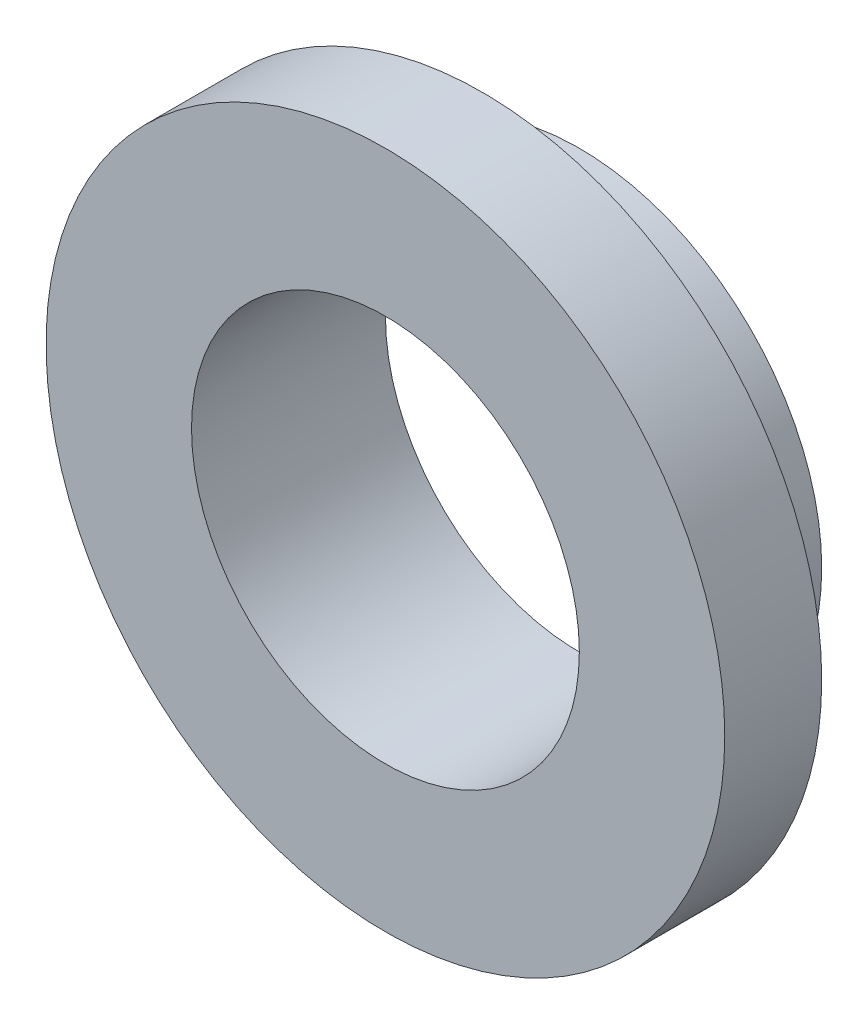
from build123d import *

# Parameters (mm, degrees)
SKIZZE1_R                       = 2.5
SKIZZE1_R_2                     = 2
AUFSATZ_LINEAR_AUSTRAGEN1_DEPTH = 1
SKIZZE2_R                       = 3.5
SKIZZE2_R_2                     = 2
AUFSATZ_LINEAR_AUSTRAGEN2_DEPTH = 1


with BuildPart() as part:
    # Skizze1 → Aufsatz-Linear austragen1 (new body, symmetric)
    with BuildSketch(Plane.XY):
        Circle(SKIZZE1_R)
        Circle(SKIZZE1_R_2, mode=Mode.SUBTRACT)
    extrude(amount=AUFSATZ_LINEAR_AUSTRAGEN1_DEPTH, both=True)

    # Skizze2 → Aufsatz-Linear austragen2 (add)
    with BuildSketch(Plane.XY.offset(1)):
        Circle(SKIZZE2_R)
        Circle(SKIZZE2_R_2, mode=Mode.SUBTRACT)
    extrude(amount=-AUFSATZ_LINEAR_AUSTRAGEN2_DEPTH)


solid = part.part
